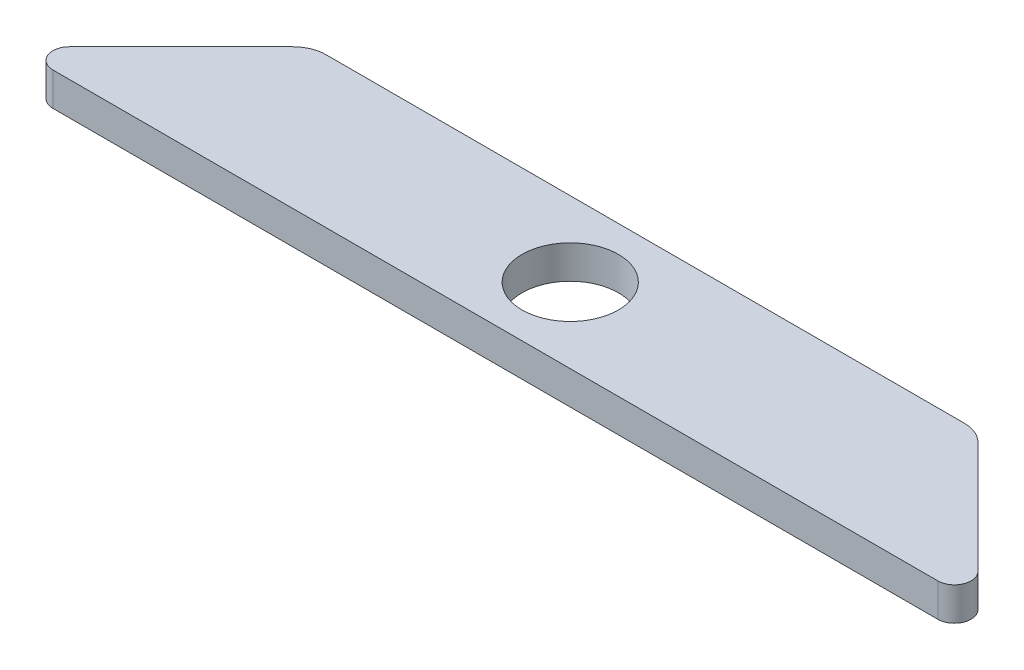
from build123d import *

# Parameters (mm, degrees)
BOSS_EXTRUDE1_DEPTH = 0.5
CUT_EXTRUDE1_REACH  = 3
SKETCH2_R           = 1.4478


with BuildPart() as part:
    # Sketch1 → Boss-Extrude1 (new body, symmetric)
    with BuildSketch(Plane(origin=(0, 0, 0), x_dir=(1, 0, 0), z_dir=(0, 1, 0))):
        with BuildLine():
            Line((-13.292893219, -2.530330086), (13.292893219, -2.530330086))
            ThreePointArc((13.292893219, -2.530330086), (13.754832985, -2.221671802), (13.646446609, -1.676776695))
            Line((13.646446609, -1.676776695), (10.292893219, 1.676776695))
            ThreePointArc((10.292893219, 1.676776695), (9.96846987, 1.893549447), (9.585786438, 1.969669914))
            Line((9.585786438, 1.969669914), (-9.585786438, 1.969669914))
            ThreePointArc((-9.585786438, 1.969669914), (-9.96846987, 1.893549447), (-10.292893219, 1.676776695))
            Line((-10.292893219, 1.676776695), (-13.646446609, -1.676776695))
            ThreePointArc((-13.646446609, -1.676776695), (-13.754832985, -2.221671802), (-13.292893219, -2.530330086))
        make_face()
    extrude(amount=BOSS_EXTRUDE1_DEPTH, both=True)

    # Sketch2 → Cut-Extrude1 (cut, up to next)
    with BuildSketch(Plane(origin=(0, 0.5, 0), x_dir=(1, 0, 0), z_dir=(0, 1, 0)), mode=Mode.PRIVATE) as cut_extrude1_sk1:
        with Locations((0, -0.280330086)):
            Circle(SKETCH2_R)
    cut_extrude1_tool1 = extrude(cut_extrude1_sk1.sketch, amount=-CUT_EXTRUDE1_REACH, mode=Mode.PRIVATE) & part.part
    add(cut_extrude1_tool1.solids().sort_by_distance((0, 0.5, 0.28033))[0], mode=Mode.SUBTRACT)


solid = part.part
